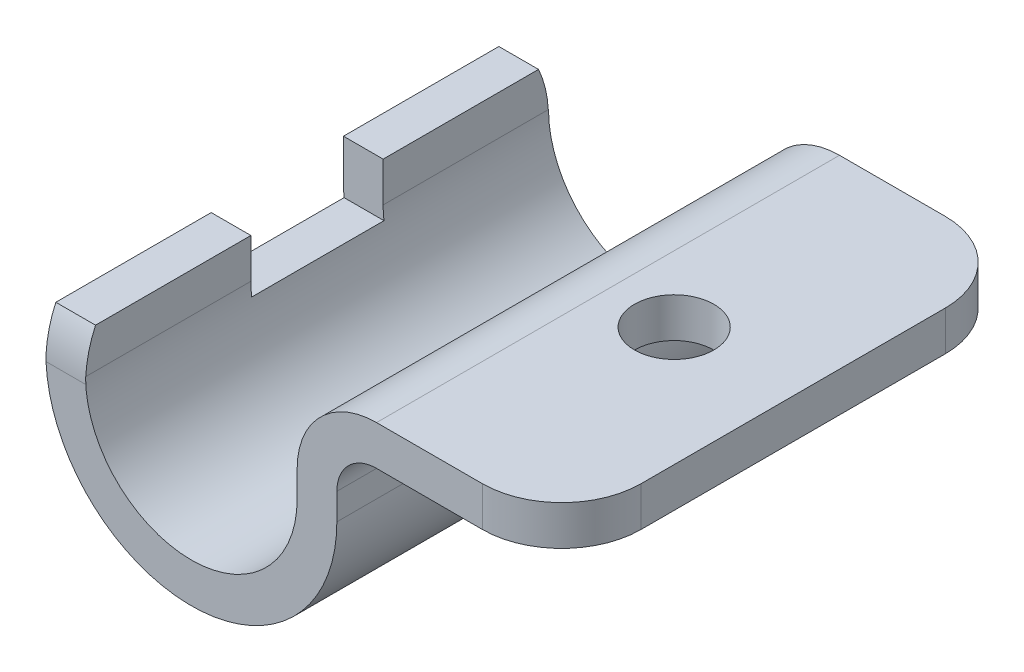
from build123d import *

# Parameters (mm, degrees)
EXTRUSION1_DEPTH        = 17.5
CONG_1_R                = 6
ESQUISSE2_R             = 3
ENL_V_MAT_EXTRU_1_DEPTH = 20
ENL_V_MAT_EXTRU_6_DEPTH = 35
ESQUISSE4_W             = 10
ESQUISSE4_H             = 4
ENL_V_MAT_EXTRU_7_DEPTH = 12.0000001


with BuildPart() as part:
    # Esquisse1 → Extrusion1 (new body, symmetric)
    with BuildSketch(Plane.XY):
        with BuildLine():
            Line((8, 2), (8, 0))
            ThreePointArc((8, 0), (0, -8), (-8, 0))
            Line((-8, 0), (-8, 3))
            Line((-8, 3), (-11, 3))
            Line((-11, 3), (-11, 0))
            ThreePointArc((-11, 0), (0, -11), (11, 0))
            Line((11, 0), (11, 2))
            ThreePointArc((11, 2), (11.878679656, 4.121320344), (14, 5))
            Line((14, 5), (28, 5))
            Line((28, 5), (28, 8))
            Line((28, 8), (14, 8))
            ThreePointArc((14, 8), (9.757359313, 6.242640687), (8, 2))
        make_face()
    extrude(amount=EXTRUSION1_DEPTH, both=True)

    # Congé1
    cong_1_edges = [part.edges().sort_by_distance(p)[0] for p in [
        (28, 6.5, -17.5),
        (28, 6.5, 17.5),
    ]]
    fillet(cong_1_edges, radius=CONG_1_R)

    # Esquisse2 → Enlèv. mat.-Extru.1 (cut, through all)
    with BuildSketch(Plane(origin=(0, 8, 0), x_dir=(-1, 0, 0), z_dir=(0, 1, 0))):
        with Locations(Location((-19, 0, 0), (0, 0, 90))):  # turned: the seam where the file's is
            Circle(ESQUISSE2_R)
    extrude(amount=-ENL_V_MAT_EXTRU_1_DEPTH, mode=Mode.SUBTRACT)

    # Esquisse3 → Enlèv. mat.-Extru.6 (cut)
    with BuildSketch(Plane.ZY.offset(8)):
        with BuildLine():
            Line((-9, 8), (-17.5, 8))
            Line((-17.5, 8), (-17.5, -0.5))
            ThreePointArc((-17.5, -0.5), (-15.01040764, 5.51040764), (-9, 8))
        make_face()
        with BuildLine():
            Line((17.5, 8), (17.5, -0.5))
            ThreePointArc((17.5, -0.5), (15.01040764, 5.51040764), (9, 8))
            Line((9, 8), (17.5, 8))
        make_face()
    extrude(amount=ENL_V_MAT_EXTRU_6_DEPTH, mode=Mode.SUBTRACT)

    # Esquisse4 → Enlèv. mat.-Extru.7 (cut, through all)
    with BuildSketch(Plane(origin=(0, 0, 0), x_dir=(0, 0, -1), z_dir=(1, 0, 0))):
        with Locations((0, 1)):
            Rectangle(ESQUISSE4_W, ESQUISSE4_H)
    extrude(amount=-ENL_V_MAT_EXTRU_7_DEPTH, mode=Mode.SUBTRACT)


solid = part.part
